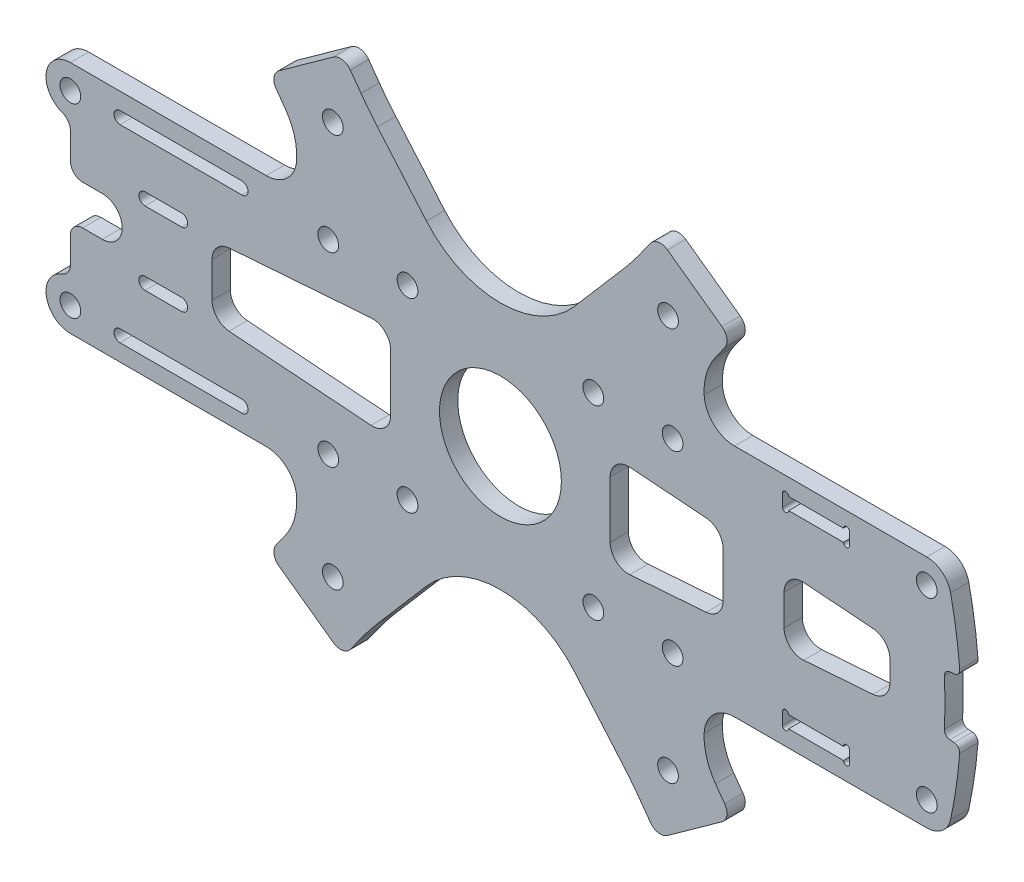
from build123d import *

# Parameters (mm, degrees)
SKETCH1_R                = 10
BOSS_EXTRUDE1_DEPTH      = 3
M3_CLEARANCE_HOLE1_D     = 3.4
M3_CLEARANCE_HOLE1_DEPTH = 3


with BuildPart() as part:
    # Sketch1 → Boss-Extrude1 (new body)
    with BuildSketch(Plane.XY):
        with BuildLine():
            Line((24.61442727, -41.149951774), (22.870757206, -38.721639656))
            ThreePointArc((22.870757206, -38.721639656), (21.560017189, -36.977835568), (20.17446104, -35.292864871))
            Line((20.17446104, -35.292864871), (12.133689221, -25.938186031))
            ThreePointArc((12.133689221, -25.938186031), (0, -20.367643634), (-12.133689221, -25.938186031))
            Line((-12.133689221, -25.938186031), (-20.17446104, -35.292864871))
            ThreePointArc((-20.17446104, -35.292864871), (-21.560017189, -36.977835568), (-22.870757206, -38.721639656))
            Line((-22.870757206, -38.721639656), (-24.61442727, -41.149951774))
            ThreePointArc((-24.61442727, -41.149951774), (-25.915112885, -41.957022207), (-27.405521478, -41.607983565))
            Line((-27.405521478, -41.607983565), (-36.340617975, -35.192061916))
            ThreePointArc((-36.340617975, -35.192061916), (-37.147688407, -33.891376301), (-36.798649765, -32.400967708))
            Line((-36.798649765, -32.400967708), (-35.293444766, -30.304752596))
            ThreePointArc((-35.293444766, -30.304752596), (-33.831407094, -27.32351713), (-33.426130009, -24.027903448))
            ThreePointArc((-33.426130009, -24.027903448), (-34.965075875, -20.636796244), (-38.421194886, -19.25))
            Line((-38.421194886, -19.25), (-70.560347596, -19.25))
            ThreePointArc((-70.560347596, -19.25), (-74.502741834, -15.926407915), (-71.893680929, -11.478763834))
            ThreePointArc((-71.893680929, -11.478763834), (-70.927354434, -10.747846289), (-70.560347596, -9.593145751))
            Line((-70.560347596, -9.593145751), (-70.560347596, -5.25))
            ThreePointArc((-70.560347596, -5.25), (-69.974561158, -3.835786438), (-68.560347596, -3.25))
            Line((-68.560347596, -3.25), (-65.309156116, -3.25))
            ThreePointArc((-65.309156116, -3.25), (-62.059156116, 0), (-65.309156116, 3.25))
            Line((-65.309156116, 3.25), (-68.560347596, 3.25))
            ThreePointArc((-68.560347596, 3.25), (-69.974561158, 3.835786438), (-70.560347596, 5.25))
            Line((-70.560347596, 5.25), (-70.560347596, 9.593145751))
            ThreePointArc((-70.560347596, 9.593145751), (-70.927354434, 10.747846289), (-71.893680929, 11.478763834))
            ThreePointArc((-71.893680929, 11.478763834), (-74.502741834, 15.926407915), (-70.560347596, 19.25))
            Line((-70.560347596, 19.25), (-38.421194886, 19.25))
            ThreePointArc((-38.421194886, 19.25), (-34.965075875, 20.636796244), (-33.426130009, 24.027903448))
            ThreePointArc((-33.426130009, 24.027903448), (-33.831407094, 27.32351713), (-35.293444766, 30.304752596))
            Line((-35.293444766, 30.304752596), (-36.798649765, 32.400967708))
            ThreePointArc((-36.798649765, 32.400967708), (-37.147688407, 33.891376301), (-36.340617975, 35.192061916))
            Line((-36.340617975, 35.192061916), (-27.405521478, 41.607983565))
            ThreePointArc((-27.405521478, 41.607983565), (-25.915112885, 41.957022207), (-24.61442727, 41.149951774))
            Line((-24.61442727, 41.149951774), (-22.870757206, 38.721639656))
            ThreePointArc((-22.870757206, 38.721639656), (-21.560017189, 36.977835568), (-20.17446104, 35.292864871))
            Line((-20.17446104, 35.292864871), (-12.133689221, 25.938186031))
            ThreePointArc((-12.133689221, 25.938186031), (0, 20.367643634), (12.133689221, 25.938186031))
            Line((12.133689221, 25.938186031), (20.17446104, 35.292864871))
            ThreePointArc((20.17446104, 35.292864871), (21.560017189, 36.977835568), (22.870757206, 38.721639656))
            Line((22.870757206, 38.721639656), (24.61442727, 41.149951774))
            ThreePointArc((24.61442727, 41.149951774), (25.915112885, 41.957022207), (27.405521478, 41.607983565))
            Line((27.405521478, 41.607983565), (36.340617975, 35.192061916))
            ThreePointArc((36.340617975, 35.192061916), (37.147688407, 33.891376301), (36.798649765, 32.400967708))
            Line((36.798649765, 32.400967708), (35.293444766, 30.304752596))
            ThreePointArc((35.293444766, 30.304752596), (33.831407094, 27.32351713), (33.426130009, 24.027903448))
            ThreePointArc((33.426130009, 24.027903448), (34.965075875, 20.636796244), (38.421194886, 19.25))
            Line((38.421194886, 19.25), (69.9498441, 19.25))
            ThreePointArc((69.9498441, 19.25), (72.459011369, 18.365137175), (73.858044218, 16.102039809))
            ThreePointArc((73.858044218, 16.102039809), (74.779973707, 11.056306534), (75.357605678, 5.959668468))
            ThreePointArc((75.357605678, 5.959668468), (75.124073885, 5.234850929), (74.447874059, 4.884634772))
            Line((74.447874059, 4.884634772), (73.745035473, 4.823144363))
            ThreePointArc((73.745035473, 4.823144363), (73.077669675, 4.483224946), (72.833531849, 3.775186077))
            ThreePointArc((72.833531849, 3.775186077), (72.931305977, 0), (72.833531849, -3.775186077))
            ThreePointArc((72.833531849, -3.775186077), (73.077669675, -4.483224946), (73.745035473, -4.823144363))
            Line((73.745035473, -4.823144363), (74.447874059, -4.884634772))
            ThreePointArc((74.447874059, -4.884634772), (75.124073885, -5.234850929), (75.357605678, -5.959668468))
            ThreePointArc((75.357605678, -5.959668468), (74.779973707, -11.056306534), (73.858044218, -16.102039809))
            ThreePointArc((73.858044218, -16.102039809), (72.459011369, -18.365137175), (69.9498441, -19.25))
            Line((69.9498441, -19.25), (38.421194886, -19.25))
            ThreePointArc((38.421194886, -19.25), (34.965075875, -20.636796244), (33.426130009, -24.027903448))
            ThreePointArc((33.426130009, -24.027903448), (33.831407094, -27.32351713), (35.293444766, -30.304752596))
            Line((35.293444766, -30.304752596), (36.798649765, -32.400967708))
            ThreePointArc((36.798649765, -32.400967708), (37.147688407, -33.891376301), (36.340617975, -35.192061916))
            Line((36.340617975, -35.192061916), (27.405521478, -41.607983565))
            ThreePointArc((27.405521478, -41.607983565), (25.915112885, -41.957022207), (24.61442727, -41.149951774))
        make_face()
        Circle(SKETCH1_R, mode=Mode.SUBTRACT)
        with BuildLine():
            Line((57.280742727, -14.5), (57.280742727, -16.5))
            ThreePointArc((57.280742727, -16.5), (56.780742727, -17), (56.280742727, -16.5))
            Line((56.280742727, -16.5), (47.280742727, -16.5))
            ThreePointArc((47.280742727, -16.5), (46.780742727, -17), (46.280742727, -16.5))
            Line((46.280742727, -16.5), (46.280742727, -14.5))
            ThreePointArc((46.280742727, -14.5), (46.780742727, -14), (47.280742727, -14.5))
            Line((47.280742727, -14.5), (56.280742727, -14.5))
            ThreePointArc((56.280742727, -14.5), (56.780742727, -14), (57.280742727, -14.5))
        make_face(mode=Mode.SUBTRACT)
        with BuildLine():
            Line((61.128681203, 4.684825598), (49.755187966, 5.524570535))
            ThreePointArc((49.755187966, 5.524570535), (47.492561232, 4.73074729), (46.534288718, 2.532714335))
            Line((46.534288718, 2.532714335), (46.534288718, -2.532714335))
            ThreePointArc((46.534288718, -2.532714335), (47.492561232, -4.73074729), (49.755187966, -5.524570535))
            Line((49.755187966, -5.524570535), (61.128681203, -4.684825598))
            ThreePointArc((61.128681203, -4.684825598), (63.077235428, -3.765038805), (63.906623732, -1.776324056))
            ThreePointArc((63.906623732, -1.776324056), (63.931305977, 0), (63.906623732, 1.776324056))
            ThreePointArc((63.906623732, 1.776324056), (63.077235428, 3.765038805), (61.128681203, 4.684825598))
        make_face(mode=Mode.SUBTRACT)
        with BuildLine():
            Line((-47.315978206, 2.918000522), (-47.315978206, -2.918000522))
            ThreePointArc((-47.315978206, -2.918000522), (-46.514011161, -4.959728008), (-44.536877453, -5.909856722))
            Line((-44.536877453, -5.909856722), (-21.220899248, -7.631357255))
            ThreePointArc((-21.220899248, -7.631357255), (-18.958272514, -6.83753401), (-18, -4.639501055))
            Line((-18, -4.639501055), (-18, 4.639501055))
            ThreePointArc((-18, 4.639501055), (-18.958272514, 6.83753401), (-21.220899248, 7.631357255))
            Line((-21.220899248, 7.631357255), (-44.536877453, 5.909856722))
            ThreePointArc((-44.536877453, 5.909856722), (-46.514011161, 4.959728008), (-47.315978206, 2.918000522))
        make_face(mode=Mode.SUBTRACT)
        with BuildLine():
            Line((21.220899248, 7.631357255), (33.755187966, 6.705906711))
            ThreePointArc((33.755187966, 6.705906711), (35.732321673, 5.755777997), (36.534288718, 3.714050511))
            Line((36.534288718, 3.714050511), (36.534288718, -3.714050511))
            ThreePointArc((36.534288718, -3.714050511), (35.732321673, -5.755777997), (33.755187966, -6.705906711))
            Line((33.755187966, -6.705906711), (21.220899248, -7.631357255))
            ThreePointArc((21.220899248, -7.631357255), (18.958272514, -6.83753401), (18, -4.639501055))
            Line((18, -4.639501055), (18, 4.639501055))
            ThreePointArc((18, 4.639501055), (18.958272514, 6.83753401), (21.220899248, 7.631357255))
        make_face(mode=Mode.SUBTRACT)
        with BuildLine():
            Line((57.280742727, 14.5), (57.280742727, 16.5))
            ThreePointArc((57.280742727, 16.5), (56.780742727, 17), (56.280742727, 16.5))
            Line((56.280742727, 16.5), (47.280742727, 16.5))
            ThreePointArc((47.280742727, 16.5), (46.780742727, 17), (46.280742727, 16.5))
            Line((46.280742727, 16.5), (46.280742727, 14.5))
            ThreePointArc((46.280742727, 14.5), (46.780742727, 14), (47.280742727, 14.5))
            Line((47.280742727, 14.5), (56.280742727, 14.5))
            ThreePointArc((56.280742727, 14.5), (56.780742727, 14), (57.280742727, 14.5))
        make_face(mode=Mode.SUBTRACT)
        with BuildLine():
            Line((-58.315978206, 7), (-52.315978206, 7))
            ThreePointArc((-52.315978206, 7), (-51.315978206, 6), (-52.315978206, 5))
            Line((-52.315978206, 5), (-58.315978206, 5))
            ThreePointArc((-58.315978206, 5), (-59.023084987, 5.292893219), (-59.315978206, 6))
            ThreePointArc((-59.315978206, 6), (-59.023084987, 6.707106781), (-58.315978206, 7))
        make_face(mode=Mode.SUBTRACT)
        with BuildLine():
            Line((-58.315978206, -7), (-52.315978206, -7))
            ThreePointArc((-52.315978206, -7), (-51.315978206, -6), (-52.315978206, -5))
            Line((-52.315978206, -5), (-58.315978206, -5))
            ThreePointArc((-58.315978206, -5), (-59.023084987, -5.292893219), (-59.315978206, -6))
            ThreePointArc((-59.315978206, -6), (-59.023084987, -6.707106781), (-58.315978206, -7))
        make_face(mode=Mode.SUBTRACT)
        with BuildLine():
            Line((-42.405173798, -14.5), (-62.405173798, -14.5))
            ThreePointArc((-62.405173798, -14.5), (-63.405173798, -15.5), (-62.405173798, -16.5))
            Line((-62.405173798, -16.5), (-42.405173798, -16.5))
            ThreePointArc((-42.405173798, -16.5), (-41.405173798, -15.5), (-42.405173798, -14.5))
        make_face(mode=Mode.SUBTRACT)
        with BuildLine():
            Line((-42.405173798, 14.5), (-62.405173798, 14.5))
            ThreePointArc((-62.405173798, 14.5), (-63.405173798, 15.5), (-62.405173798, 16.5))
            Line((-62.405173798, 16.5), (-42.405173798, 16.5))
            ThreePointArc((-42.405173798, 16.5), (-41.405173798, 15.5), (-42.405173798, 14.5))
        make_face(mode=Mode.SUBTRACT)
    extrude(amount=BOSS_EXTRUDE1_DEPTH)

    # M3 Clearance Hole1
    with Locations(Plane.XY.offset(3)):
        with Locations((-70.560347596, 15.25), (-28.25, 15.25), (-15.25, 15.25), (15.25, 15.25), (28.25, 15.25), (69.9498441, 15.25), (27.498577693, 32.307911493), (-27.498577693, 32.307911493), (15.25, -15.25), (27.498577693, -32.307911493), (-27.498577693, -32.307911493), (-15.25, -15.25), (-70.560347596, -15.25), (69.9498441, -15.25), (28.25, -15.25), (-28.25, -15.25)):
            Hole(M3_CLEARANCE_HOLE1_D / 2, depth=M3_CLEARANCE_HOLE1_DEPTH)


solid = part.part
